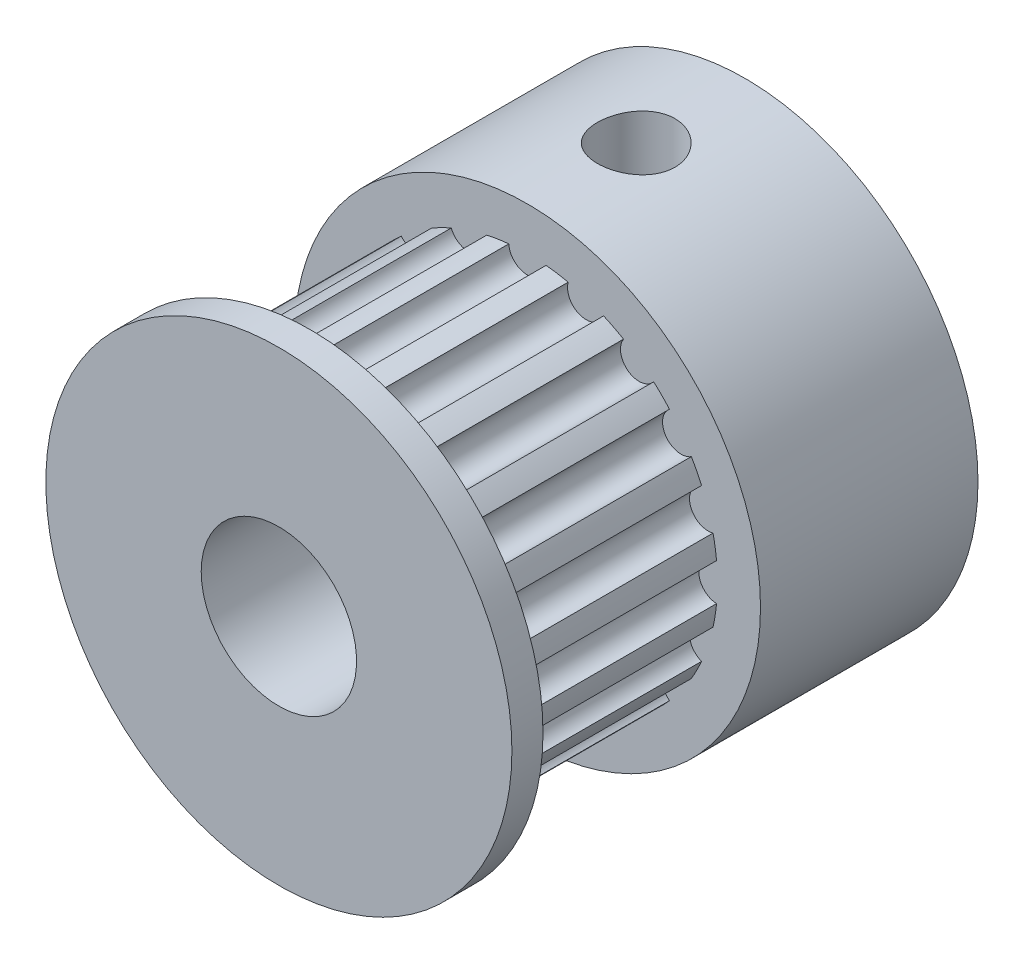
from build123d import *

# Parameters (mm, degrees)
SKETCH_1_R               = 7.5
EXTRUDE_1_DEPTH          = 3.5
SKETCH_2_R               = 6.115
EXTRUDE_2_DEPTH          = 7
CUT_EXTRUDE_3_DEPTH      = 7
SKETCH_3_R               = 7.5
EXTRUDE_3_DEPTH          = 1
SKETCH_6_R               = 2.5
CUT_EXTRUDE_2_DEPTH      = 16
PATTERN_CIRCULAR_2_COUNT = 20
SKETCH_13_W              = 1.25
SKETCH_13_H              = 7.5
PATTERN_CIRCULAR_4_COUNT = 2
PATTERN_CIRCULAR_4_ANGLE = 90


with BuildPart() as part:
    # 草圖1 → 填料-伸長1 (new body, symmetric)
    with BuildSketch(Plane.XY):
        Circle(SKETCH_1_R)
    extrude(amount=EXTRUDE_1_DEPTH, both=True)

    # 草圖2 → 填料-伸長2 (add)
    with BuildSketch(Plane.XY.offset(3.5)):
        Circle(SKETCH_2_R)
    extrude(amount=EXTRUDE_2_DEPTH)

    # 草圖7 → 除料-伸長3 (cut)
    with BuildSketch(Plane.XY.offset(10.5)):
        with BuildLine():
            ThreePointArc((-0.599277509, 6.085564186), (0, 5.515), (0.599277509, 6.085564186))
            ThreePointArc((0.599277509, 6.085564186), (0, 6.115), (-0.599277509, 6.085564186))
        make_face()
    cut_extrude_3 = extrude(amount=-CUT_EXTRUDE_3_DEPTH, mode=Mode.SUBTRACT)

    # 草圖3 → 填料-伸長3 (add)
    with BuildSketch(Plane.XY.offset(10.5)):
        Circle(SKETCH_3_R)
    extrude(amount=EXTRUDE_3_DEPTH)

    # 草圖6 → 除料-伸長2 (cut, through all)
    with BuildSketch(Plane(origin=(0, 0, -3.5), x_dir=(-1, 0, 0), z_dir=(0, 0, -1))):
        Circle(SKETCH_6_R)
    extrude(amount=-CUT_EXTRUDE_2_DEPTH, mode=Mode.SUBTRACT)

    # 環狀複製排列2: 除料-伸長3 ×20 about axis
    pattern_circular_2_axis = Axis((0, 0, 0), (0, 0, 1))
    for i in range(1, PATTERN_CIRCULAR_2_COUNT):
        add(cut_extrude_3.rotate(pattern_circular_2_axis, i * 360 / PATTERN_CIRCULAR_2_COUNT), mode=Mode.SUBTRACT)

    # 草圖13 → M3x0.5 螺紋孔3 (revolve, cut)
    with BuildSketch(Plane(origin=(0, 0, 0), x_dir=(0, 0, -1), z_dir=(1, 0, 0))):
        with Locations((0.625, 3.75)):
            Rectangle(SKETCH_13_W, SKETCH_13_H)
    m3x0_5_3 = revolve(axis=Axis((0, -6.35, 0), (0, 1, 0)), mode=Mode.SUBTRACT)

    # 環狀複製排列4: M3x0.5 螺紋孔3 ×2 about axis
    pattern_circular_4_axis = Axis((0, 0, 3.5), (0, 0, 1))
    for i in range(1, PATTERN_CIRCULAR_4_COUNT):
        add(m3x0_5_3.rotate(pattern_circular_4_axis, i * PATTERN_CIRCULAR_4_ANGLE / (PATTERN_CIRCULAR_4_COUNT - 1)), mode=Mode.SUBTRACT)


solid = part.part
